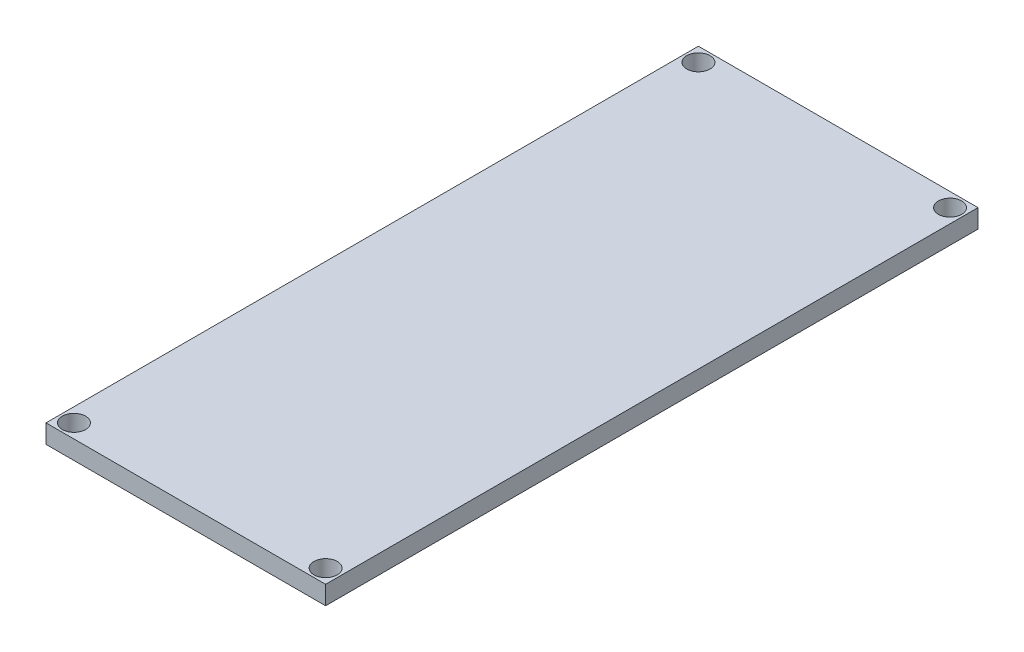
from build123d import *

# Parameters (mm, degrees)
SKETCH1_W           = 30
SKETCH1_H           = 70
BOSS_EXTRUDE1_DEPTH = 2
SKETCH2_R           = 1.25
CUT_EXTRUDE1_DEPTH  = 2


with BuildPart() as part:
    # Sketch1 → Boss-Extrude1 (new body)
    with BuildSketch(Plane(origin=(0, 0, 0), x_dir=(1, 0, 0), z_dir=(0, 1, 0))):
        Rectangle(SKETCH1_W, SKETCH1_H)
    extrude(amount=BOSS_EXTRUDE1_DEPTH)

    # Sketch2 → Cut-Extrude1 (cut)
    with BuildSketch(Plane(origin=(0, 2, 0), x_dir=(1, 0, 0), z_dir=(0, 1, 0))):
        with Locations((-13.5, 33.5)):
            Circle(SKETCH2_R)
        with Locations((13.5, 33.5)):
            Circle(SKETCH2_R)
        with Locations((13.5, -33.5)):
            Circle(SKETCH2_R)
        with Locations((-13.5, -33.5)):
            Circle(SKETCH2_R)
    extrude(amount=-CUT_EXTRUDE1_DEPTH, mode=Mode.SUBTRACT)


solid = part.part
